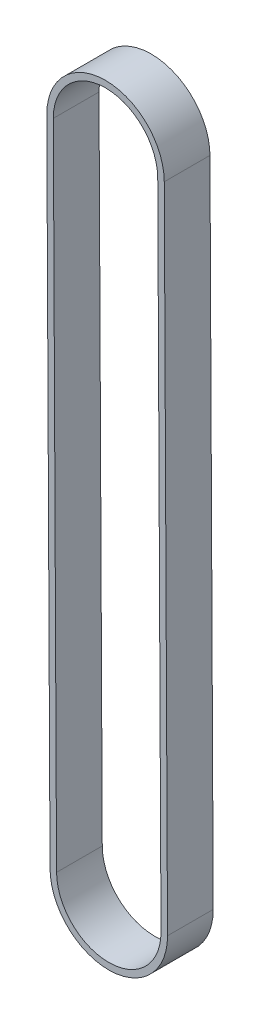
from build123d import *

# Parameters (mm, degrees)
EXTRUDE_THIN1_START = -3.5
EXTRUDE_THIN1_DEPTH = 3.5


with BuildPart() as part:
    # Sketch2 → Extrude-Thin1 (new, symmetric)
    with BuildSketch(Plane.XY.offset(EXTRUDE_THIN1_START)):
        with BuildLine():
            Line((-8.499887028, -99.835094133), (-8.999887028, -0.045094133))
            ThreePointArc((-8.999887028, -0.045094133), (-0.045094133, 8.999887028), (8.999887028, 0.045094133))
            Line((8.999887028, 0.045094133), (9.499887028, -99.744905867))
            ThreePointArc((9.499887028, -99.744905867), (0.545094133, -108.789887028), (-8.499887028, -99.835094133))
        make_face()
        with BuildLine():
            Line((-7.499899581, -99.830083674), (-7.999899581, -0.040083674))
            ThreePointArc((-7.999899581, -0.040083674), (-0.040083674, 7.999899581), (7.999899581, 0.040083674))
            Line((7.999899581, 0.040083674), (8.499899581, -99.749916326))
            ThreePointArc((8.499899581, -99.749916326), (0.540083674, -107.789899581), (-7.499899581, -99.830083674))
        make_face(mode=Mode.SUBTRACT)
    extrude(amount=EXTRUDE_THIN1_DEPTH, both=True)


solid = part.part
